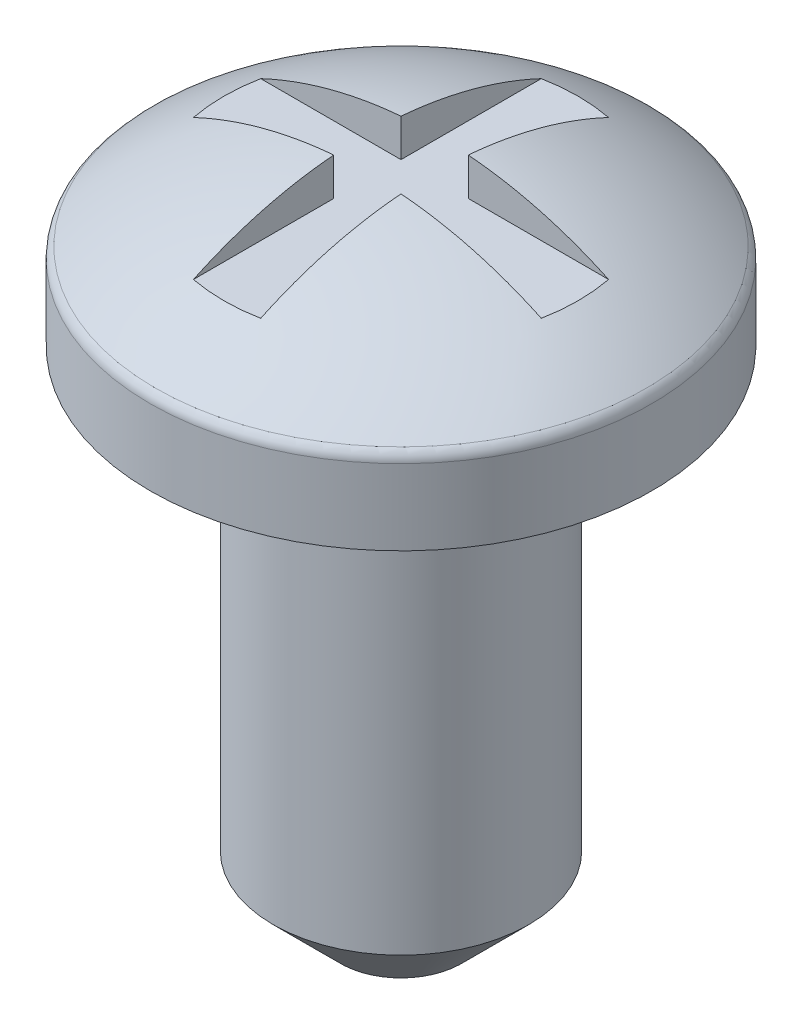
from build123d import *

# Parameters (mm, degrees)
CUT_EXTRUDE1_DEPTH = 0.635
CIRPATTERN1_COUNT  = 4
CHAMFER1_SIZE      = 1.27
FILLET1_R          = 0.254


with BuildPart() as part:
    # Sketch1 → Revolve1 (revolve)
    with BuildSketch(Plane.XY):
        with BuildLine():
            Line((0, 0), (2.413, 0))
            Line((2.413, 0), (2.413, 9.525))
            Line((2.413, 9.525), (4.7371, 9.525))
            Line((4.7371, 9.525), (4.7371, 11.076185676))
            ThreePointArc((4.7371, 11.076185676), (2.503841517, 12.282774321), (0, 12.7))
            Line((0, 12.7), (0, 0))
        make_face()
    revolve(axis=Axis((0, 0, 0), (0, 1, 0)))

    # Sketch2 → Cut-Extrude1 (cut, symmetric)
    with BuildSketch(Plane.XY):
        with BuildLine():
            Line((0, 12.7), (0, 11.938))
            Line((0, 11.938), (3.344708418, 11.938))
            ThreePointArc((3.344708418, 11.938), (1.71520541, 12.507090255), (0, 12.7))
        make_face()
    cut_extrude1 = extrude(amount=CUT_EXTRUDE1_DEPTH, both=True, mode=Mode.SUBTRACT)

    # CirPattern1: Cut-Extrude1 ×4 about axis
    cirpattern1_axis = Axis((0, 0, 0), (0, 1, 0))
    for i in range(1, CIRPATTERN1_COUNT):
        add(cut_extrude1.rotate(cirpattern1_axis, i * 360 / CIRPATTERN1_COUNT), mode=Mode.SUBTRACT)

    # Chamfer1
    chamfer1_edges = [part.edges().sort_by_distance(p)[0] for p in [
        (-2.413, 0, 0),
    ]]
    chamfer(chamfer1_edges, length=CHAMFER1_SIZE)

    # Fillet1
    fillet1_edges = [part.edges().sort_by_distance(p)[0] for p in [
        (-4.7371, 11.076185676, 0),
    ]]
    fillet(fillet1_edges, radius=FILLET1_R)


solid = part.part
